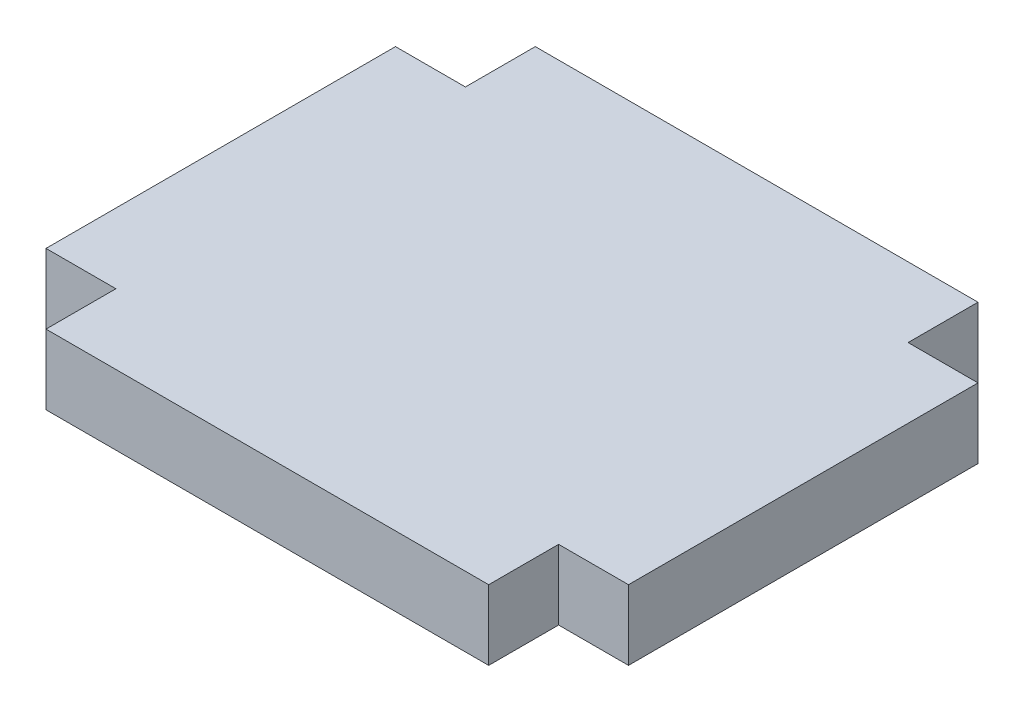
from build123d import *

# Parameters (mm, degrees)
BOSS_EXTRUDE1_DEPTH = 1.5


with BuildPart() as part:
    # Sketch1 → Boss-Extrude1 (new body, symmetric)
    with BuildSketch(Plane(origin=(0, 0, 0), x_dir=(1, 0, 0), z_dir=(0, 1, 0))):
        Polygon((-9.5, 10.5), (9.5, 10.5), (9.5, 7.5), (12.5, 7.5), (12.5, -7.5), (9.5, -7.5), (9.5, -10.5), (-9.5, -10.5), (-9.5, -7.5), (-12.5, -7.5), (-12.5, 7.5), (-9.5, 7.5), align=None)
    extrude(amount=BOSS_EXTRUDE1_DEPTH, both=True)


solid = part.part
